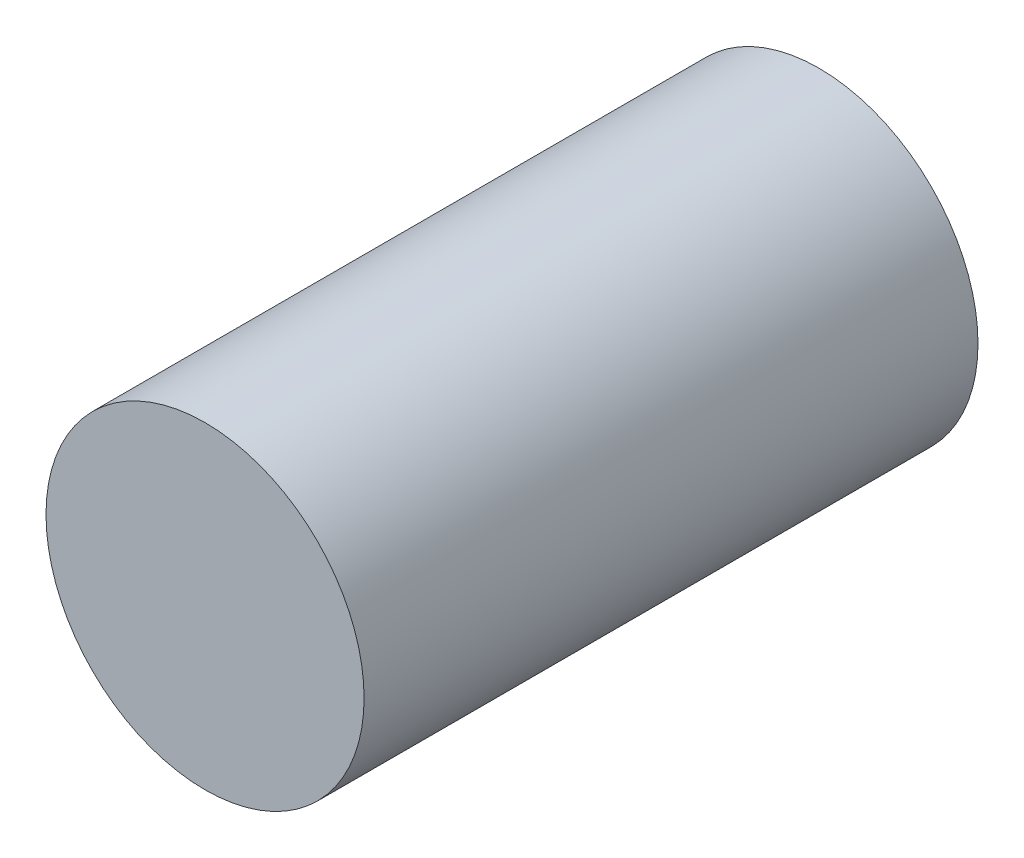
from build123d import *

# Parameters (mm, degrees)
SKETCH1_R           = 1
BOSS_EXTRUDE1_DEPTH = 1.93


with BuildPart() as part:
    # Sketch1 → Boss-Extrude1 (new body, symmetric)
    with BuildSketch(Plane.XY):
        Circle(SKETCH1_R)
    extrude(amount=BOSS_EXTRUDE1_DEPTH, both=True)


solid = part.part
